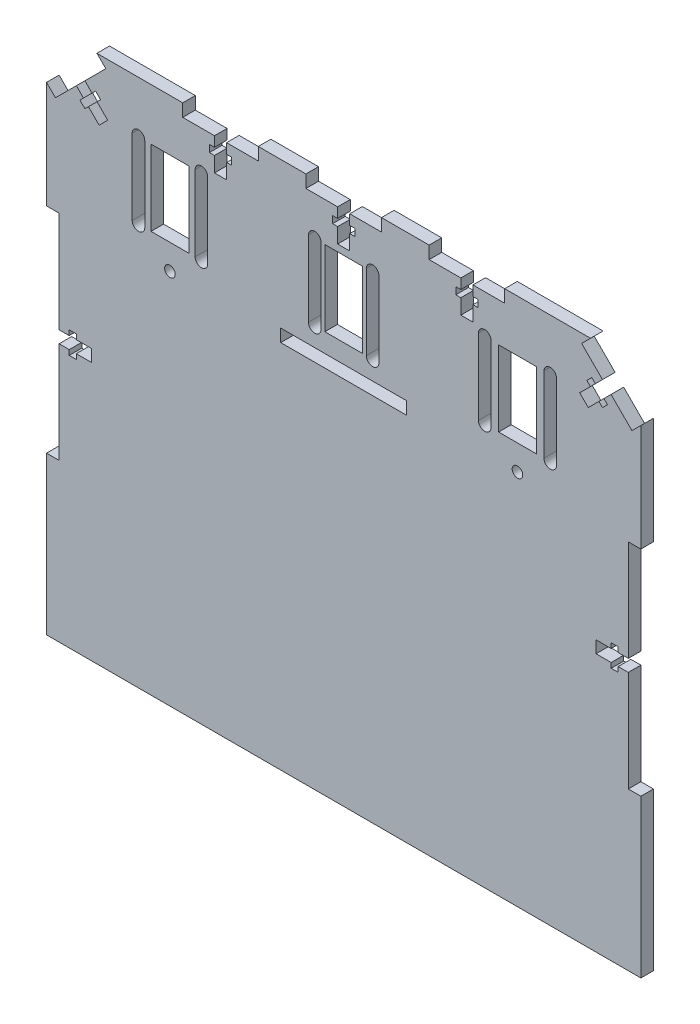
from build123d import *

# Parameters (mm, degrees)
BOSS_EXTRUDE1_DEPTH = 5
SKETCH4_W           = 5
SKETCH4_H           = 85
CUT_EXTRUDE3_DEPTH  = 6
CUT_EXTRUDE6_DEPTH  = 6
CUT_EXTRUDE8_DEPTH  = 5
SKETCH10_R          = 2.1
SKETCH10_W          = 50
SKETCH10_H          = 5
SKETCH10_W_2        = 15
SKETCH10_H_2        = 30
CUT_EXTRUDE9_DEPTH  = 10
CUT_EXTRUDE10_DEPTH = 10


with BuildPart() as part:
    # Sketch1 → Boss-Extrude1 (new body)
    with BuildSketch(Plane.XY):
        Polygon((64.226162893, -107), (118, -107), (118, 83), (98, 103), (-98, 103), (-118, 83), (-118, -107), (-64.226162893, -107), align=None)
    extrude(amount=BOSS_EXTRUDE1_DEPTH)

    # Sketch4 → Cut-Extrude3 (cut, through all)
    with BuildSketch(Plane.XY.offset(5)):
        with Locations((-115.5, -2)):
            Rectangle(SKETCH4_W, SKETCH4_H)
        with Locations((115.5, -2)):
            Rectangle(SKETCH4_W, SKETCH4_H)
    extrude(amount=-CUT_EXTRUDE3_DEPTH, mode=Mode.SUBTRACT)

    # Sketch7 → Cut-Extrude6 (cut, through all)
    with BuildSketch(Plane.XY.offset(5)):
        Polygon((-15, 98), (-2.4, 98), (-2.4, 94), (-4.4, 94), (-4.4, 91.2), (-2.4, 91.2), (-2.4, 85.2), (2.4, 85.2), (2.4, 91.2), (4.4, 91.2), (4.4, 94), (2.4, 94), (2.4, 98), (15, 98), (15, 103), (-15, 103), align=None)
        Polygon((-51.315063509, 98), (-63.915063509, 98), (-63.915063509, 103), (-33.915063509, 103), (-33.915063509, 98), (-46.515063509, 98), (-46.515063509, 94), (-44.515063509, 94), (-44.515063509, 91.2), (-46.515063509, 91.2), (-46.515063509, 85.2), (-51.315063509, 85.2), (-51.315063509, 91.2), (-53.315063509, 91.2), (-53.315063509, 94), (-51.315063509, 94), align=None)
        Polygon((-102.765899705, 91.163032483), (-99.93747258, 88.334605358), (-98.523259018, 89.748818921), (-96.543360031, 87.768919933), (-97.957573593, 86.354706371), (-93.714932906, 82.112065684), (-97.109045456, 78.717953134), (-101.351686143, 82.960593821), (-102.765899705, 81.546380259), (-104.745798693, 83.526279246), (-103.33158513, 84.940492808), (-106.160012255, 87.768919933), align=None)
        Polygon((93.714932906, 82.112065684), (97.109045456, 78.717953134), (101.351686143, 82.960593821), (102.765899705, 81.546380259), (104.745798693, 83.526279246), (103.33158513, 84.940492808), (106.160012255, 87.768919933), (102.765899705, 91.163032483), (99.93747258, 88.334605358), (98.523259018, 89.748818921), (96.543360031, 87.768919933), (97.957573593, 86.354706371), align=None)
        Polygon((33.915063509, 98), (46.515063509, 98), (46.515063509, 94), (44.515063509, 94), (44.515063509, 91.2), (46.515063509, 91.2), (46.515063509, 85.2), (51.315063509, 85.2), (51.315063509, 91.2), (53.315063509, 91.2), (53.315063509, 94), (51.315063509, 94), (51.315063509, 98), (63.915063509, 98), (63.915063509, 103), (33.915063509, 103), align=None)
    extrude(amount=-CUT_EXTRUDE6_DEPTH, mode=Mode.SUBTRACT)

    # Sketch9 → Cut-Extrude8 (cut)
    with BuildSketch(Plane.XY.offset(5)):
        Polygon((94.467486322, 99.461445866), (98, 103), (118, 83), (114.464466094, 79.464466094), align=None)
        Polygon((-118, 83), (-114.461445866, 79.467486322), (-94.464466094, 99.464466094), (-98, 103), align=None)
    extrude(amount=-CUT_EXTRUDE8_DEPTH, mode=Mode.SUBTRACT)

    # Sketch10 → Cut-Extrude9 (cut)
    with BuildSketch(Plane.XY.offset(5)):
        with Locations((69, 42.5)):
            Circle(SKETCH10_R)
        with Locations((-69, 42.5)):
            Circle(SKETCH10_R)
        with Locations((0, 42.5)):
            Rectangle(SKETCH10_W, SKETCH10_H)
        with Locations((-69, 67.5)):
            Rectangle(SKETCH10_W_2, SKETCH10_H_2)
        with Locations((0, 67.5)):
            Rectangle(SKETCH10_W_2, SKETCH10_H_2)
        with Locations((69, 67.5)):
            Rectangle(SKETCH10_W_2, SKETCH10_H_2)
        with BuildLine():
            Line((-54, 82.5), (-54, 52.5))
            ThreePointArc((-54, 52.5), (-56.5, 50), (-59, 52.5))
            Line((-59, 52.5), (-59, 82.5))
            ThreePointArc((-59, 82.5), (-56.5, 85), (-54, 82.5))
        make_face()
        with BuildLine():
            Line((-9, 82.5), (-9, 52.5))
            ThreePointArc((-9, 52.5), (-11.5, 50), (-14, 52.5))
            Line((-14, 52.5), (-14, 82.5))
            ThreePointArc((-14, 82.5), (-11.5, 85), (-9, 82.5))
        make_face()
        with BuildLine():
            Line((58.5, 82.5), (58.5, 52.5))
            ThreePointArc((58.5, 52.5), (56, 50), (53.5, 52.5))
            Line((53.5, 52.5), (53.5, 82.5))
            ThreePointArc((53.5, 82.5), (56, 85), (58.5, 82.5))
        make_face()
        with BuildLine():
            Line((-84, 82.5), (-84, 52.5))
            ThreePointArc((-84, 52.5), (-81.5, 50), (-79, 52.5))
            Line((-79, 52.5), (-79, 82.5))
            ThreePointArc((-79, 82.5), (-81.5, 85), (-84, 82.5))
        make_face()
        with BuildLine():
            Line((9, 82.5), (9, 52.5))
            ThreePointArc((9, 52.5), (11.5, 50), (14, 52.5))
            Line((14, 52.5), (14, 82.5))
            ThreePointArc((14, 82.5), (11.5, 85), (9, 82.5))
        make_face()
        with BuildLine():
            Line((79.5, 82.5), (79.5, 52.5))
            ThreePointArc((79.5, 52.5), (82, 50), (84.5, 52.5))
            Line((84.5, 52.5), (84.5, 82.5))
            ThreePointArc((84.5, 82.5), (82, 85), (79.5, 82.5))
        make_face()
    extrude(amount=-CUT_EXTRUDE9_DEPTH, mode=Mode.SUBTRACT)

    # Sketch11 → Cut-Extrude10 (cut)
    with BuildSketch(Plane.XY.offset(5)):
        Polygon((-113, 0.4), (-109, 0.4), (-109, 2.4), (-106.2, 2.4), (-106.2, 0.4), (-100.2, 0.4), (-100.2, -4.4), (-106.2, -4.4), (-106.2, -6.4), (-109, -6.4), (-109, -4.4), (-113, -4.4), align=None)
        Polygon((113, 0.4), (113, -4.4), (109, -4.4), (109, -6.4), (106.2, -6.4), (106.2, -4.4), (100.2, -4.4), (100.2, 0.4), (106.2, 0.4), (106.2, 2.4), (109, 2.4), (109, 0.4), align=None)
    extrude(amount=-CUT_EXTRUDE10_DEPTH, mode=Mode.SUBTRACT)


solid = part.part
